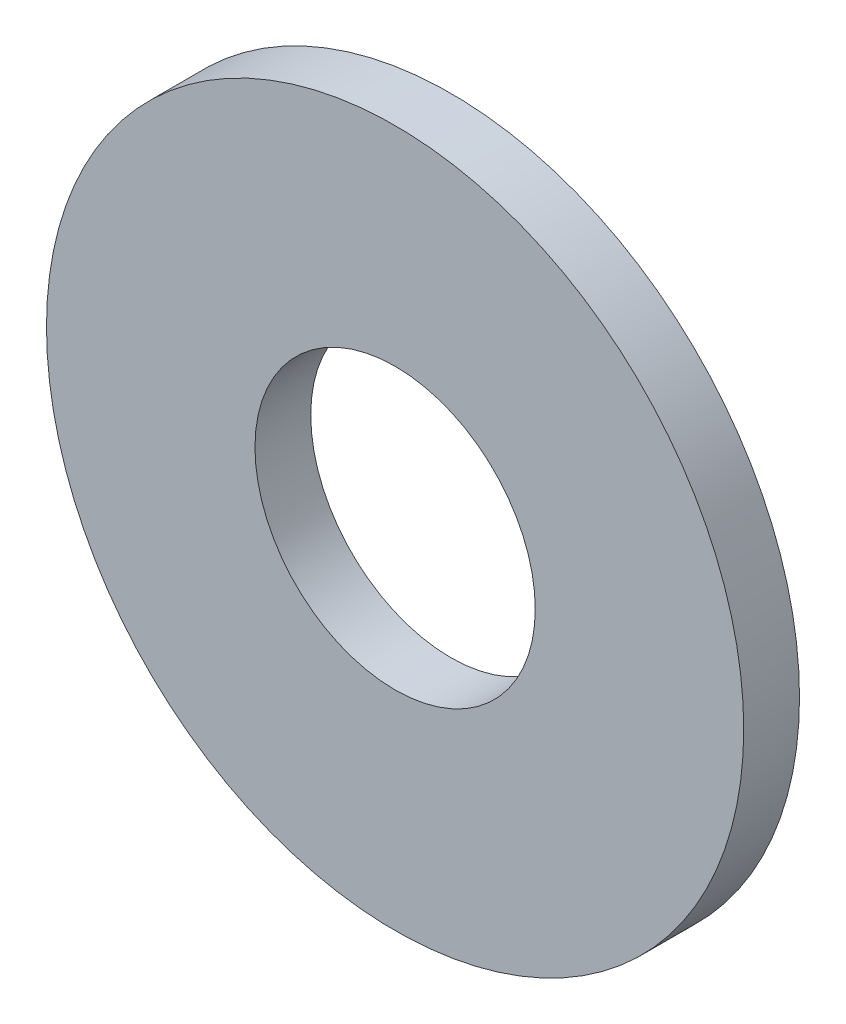
from build123d import *

# Parameters (mm, degrees)
SKETCH1_R           = 6.35
SKETCH1_R_2         = 2.5527
BOSS_EXTRUDE1_DEPTH = 1.016


with BuildPart() as part:
    # Sketch1 → Boss-Extrude1 (new body)
    with BuildSketch(Plane.XY):
        Circle(SKETCH1_R)
        Circle(SKETCH1_R_2, mode=Mode.SUBTRACT)
    extrude(amount=BOSS_EXTRUDE1_DEPTH)


solid = part.part
